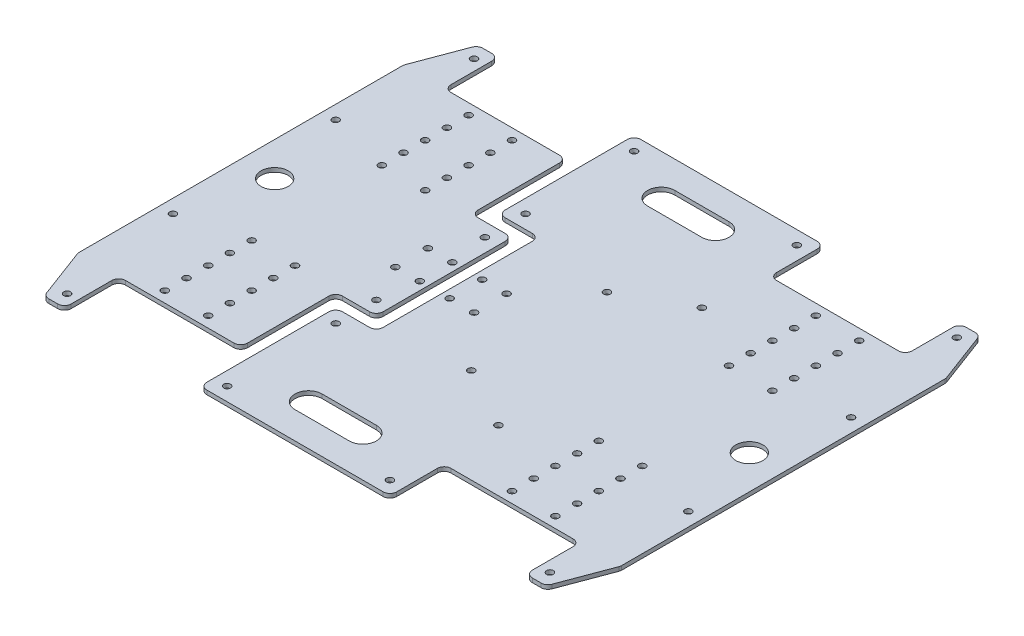
from build123d import *

# Parameters (mm, degrees)
SKETCH_1_R        = 2.5
SKETCH_1_R_2      = 10
EXTRUDE_1_DEPTH   = 3
EXTRUDE_1_2_DEPTH = 3


with BuildPart() as part:
    # 草图1 → 凸台-拉伸1 (new body)
    with BuildSketch(Plane(origin=(0, 0, 0), x_dir=(1, 0, 0), z_dir=(0, 1, 0))):
        with BuildLine():
            Line((-200, -119.093327091), (-200, 119.093327091))
            ThreePointArc((-200, 119.093327091), (-199.919767751, 119.985451119), (-199.681645888, 120.848944299))
            Line((-199.681645888, 120.848944299), (-186.216643547, 156.755617208))
            ThreePointArc((-186.216643547, 156.755617208), (-184.382971848, 159.109628088), (-181.534997659, 160))
            Line((-181.534997659, 160), (-175, 160))
            ThreePointArc((-175, 160), (-171.464466094, 158.535533906), (-170, 155))
            Line((-170, 155), (-170, 125))
            ThreePointArc((-170, 125), (-168.535533906, 121.464466094), (-165, 120))
            Line((-165, 120), (-85, 120))
            ThreePointArc((-85, 120), (-81.464466094, 118.535533906), (-80, 115))
            Line((-80, 115), (-80, 55))
            ThreePointArc((-80, 55), (-78.535533906, 51.464466094), (-75, 50))
            Line((-75, 50), (-55, 50))
            ThreePointArc((-55, 50), (-51.464466094, 48.535533906), (-50, 45))
            Line((-50, 45), (-50, -45))
            ThreePointArc((-50, -45), (-51.464466094, -48.535533906), (-55, -50))
            Line((-55, -50), (-75, -50))
            ThreePointArc((-75, -50), (-78.535533906, -51.464466094), (-80, -55))
            Line((-80, -55), (-80, -115))
            ThreePointArc((-80, -115), (-81.464466094, -118.535533906), (-85, -120))
            Line((-85, -120), (-165, -120))
            ThreePointArc((-165, -120), (-168.535533906, -121.464466094), (-170, -125))
            Line((-170, -125), (-170, -155))
            ThreePointArc((-170, -155), (-171.464466094, -158.535533906), (-175, -160))
            Line((-175, -160), (-181.534997659, -160))
            ThreePointArc((-181.534997659, -160), (-184.382971848, -159.109628088), (-186.216643547, -156.755617208))
            Line((-186.216643547, -156.755617208), (-199.681645888, -120.848944299))
            ThreePointArc((-199.681645888, -120.848944299), (-199.919767751, -119.985451119), (-200, -119.093327091))
        make_face()
        with Locations((-112, 112)):
            Circle(SKETCH_1_R, mode=Mode.SUBTRACT)
        with Locations((-144, 112)):
            Circle(SKETCH_1_R, mode=Mode.SUBTRACT)
        with Locations((-144, 96)):
            Circle(SKETCH_1_R, mode=Mode.SUBTRACT)
        with Locations((-144, 80)):
            Circle(SKETCH_1_R, mode=Mode.SUBTRACT)
        with Locations((-144, 64)):
            Circle(SKETCH_1_R, mode=Mode.SUBTRACT)
        with Locations((-144, 48)):
            Circle(SKETCH_1_R, mode=Mode.SUBTRACT)
        with Locations((-112, 96)):
            Circle(SKETCH_1_R, mode=Mode.SUBTRACT)
        with Locations((-112, 80)):
            Circle(SKETCH_1_R, mode=Mode.SUBTRACT)
        with Locations((-112, 64)):
            Circle(SKETCH_1_R, mode=Mode.SUBTRACT)
        with Locations((-112, 48)):
            Circle(SKETCH_1_R, mode=Mode.SUBTRACT)
        with Locations((-56, 12)):
            Circle(SKETCH_1_R, mode=Mode.SUBTRACT)
        with Locations((-74, 12)):
            Circle(SKETCH_1_R, mode=Mode.SUBTRACT)
        with Locations((-178, 150)):
            Circle(SKETCH_1_R, mode=Mode.SUBTRACT)
        with Locations((-60, 40)):
            Circle(SKETCH_1_R, mode=Mode.SUBTRACT)
        with Locations((-190, 60)):
            Circle(SKETCH_1_R, mode=Mode.SUBTRACT)
        with Locations((-175, 0)):
            Circle(SKETCH_1_R_2, mode=Mode.SUBTRACT)
        with Locations((-190, -60)):
            Circle(SKETCH_1_R, mode=Mode.SUBTRACT)
        with Locations((-60, -40)):
            Circle(SKETCH_1_R, mode=Mode.SUBTRACT)
        with Locations((-178, -150)):
            Circle(SKETCH_1_R, mode=Mode.SUBTRACT)
        with Locations((-74, -12)):
            Circle(SKETCH_1_R, mode=Mode.SUBTRACT)
        with Locations((-56, -12)):
            Circle(SKETCH_1_R, mode=Mode.SUBTRACT)
        with Locations((-112, -48)):
            Circle(SKETCH_1_R, mode=Mode.SUBTRACT)
        with Locations((-112, -64)):
            Circle(SKETCH_1_R, mode=Mode.SUBTRACT)
        with Locations((-112, -80)):
            Circle(SKETCH_1_R, mode=Mode.SUBTRACT)
        with Locations((-112, -96)):
            Circle(SKETCH_1_R, mode=Mode.SUBTRACT)
        with Locations((-144, -48)):
            Circle(SKETCH_1_R, mode=Mode.SUBTRACT)
        with Locations((-144, -64)):
            Circle(SKETCH_1_R, mode=Mode.SUBTRACT)
        with Locations((-144, -80)):
            Circle(SKETCH_1_R, mode=Mode.SUBTRACT)
        with Locations((-144, -96)):
            Circle(SKETCH_1_R, mode=Mode.SUBTRACT)
        with Locations((-144, -112)):
            Circle(SKETCH_1_R, mode=Mode.SUBTRACT)
        with Locations((-112, -112)):
            Circle(SKETCH_1_R, mode=Mode.SUBTRACT)
    extrude(amount=EXTRUDE_1_DEPTH)


with BuildPart() as body_2:
    # 草图1 → Extrude 1 2 (new body)
    with BuildSketch(Plane(origin=(0, 0, 0), x_dir=(1, 0, 0), z_dir=(0, 1, 0))):
        with BuildLine():
            Line((-70, 120), (-70, 65))
            ThreePointArc((-70, 65), (-68.535533906, 61.464466094), (-65, 60))
            Line((-65, 60), (-45, 60))
            ThreePointArc((-45, 60), (-41.464466094, 58.535533906), (-40, 55))
            Line((-40, 55), (-40, -55))
            ThreePointArc((-40, -55), (-41.464466094, -58.535533906), (-45, -60))
            Line((-45, -60), (-65, -60))
            ThreePointArc((-65, -60), (-68.535533906, -61.464466094), (-70, -65))
            Line((-70, -65), (-70, -120))
            Line((-70, -120), (-70, -155))
            ThreePointArc((-70, -155), (-68.535533906, -158.535533906), (-65, -160))
            Line((-65, -160), (65, -160))
            ThreePointArc((65, -160), (68.535533906, -158.535533906), (70, -155))
            Line((70, -155), (70, -125))
            ThreePointArc((70, -125), (71.464466094, -121.464466094), (75, -120))
            Line((75, -120), (165, -120))
            ThreePointArc((165, -120), (168.535533906, -121.464466094), (170, -125))
            Line((170, -125), (170, -155))
            ThreePointArc((170, -155), (171.464466094, -158.535533906), (175, -160))
            Line((175, -160), (181.534997659, -160))
            ThreePointArc((181.534997659, -160), (184.382971848, -159.109628088), (186.216643547, -156.755617208))
            Line((186.216643547, -156.755617208), (199.681645888, -120.848944299))
            ThreePointArc((199.681645888, -120.848944299), (199.919767751, -119.985451119), (200, -119.093327091))
            Line((200, -119.093327091), (200, 119.093327091))
            ThreePointArc((200, 119.093327091), (199.919767751, 119.985451119), (199.681645888, 120.848944299))
            Line((199.681645888, 120.848944299), (186.216643547, 156.755617208))
            ThreePointArc((186.216643547, 156.755617208), (184.382971848, 159.109628088), (181.534997659, 160))
            Line((181.534997659, 160), (175, 160))
            ThreePointArc((175, 160), (171.464466094, 158.535533906), (170, 155))
            Line((170, 155), (170, 125))
            ThreePointArc((170, 125), (168.535533906, 121.464466094), (165, 120))
            Line((165, 120), (75, 120))
            ThreePointArc((75, 120), (71.464466094, 121.464466094), (70, 125))
            Line((70, 125), (70, 155))
            ThreePointArc((70, 155), (68.535533906, 158.535533906), (65, 160))
            Line((65, 160), (-65, 160))
            ThreePointArc((-65, 160), (-68.535533906, 158.535533906), (-70, 155))
            Line((-70, 155), (-70, 120))
        make_face()
        with Locations((112, 112)):
            Circle(SKETCH_1_R, mode=Mode.SUBTRACT)
        with Locations((144, 112)):
            Circle(SKETCH_1_R, mode=Mode.SUBTRACT)
        with Locations((144, 96)):
            Circle(SKETCH_1_R, mode=Mode.SUBTRACT)
        with Locations((144, 80)):
            Circle(SKETCH_1_R, mode=Mode.SUBTRACT)
        with Locations((144, 64)):
            Circle(SKETCH_1_R, mode=Mode.SUBTRACT)
        with Locations((144, 48)):
            Circle(SKETCH_1_R, mode=Mode.SUBTRACT)
        with Locations((112, 96)):
            Circle(SKETCH_1_R, mode=Mode.SUBTRACT)
        with Locations((112, 80)):
            Circle(SKETCH_1_R, mode=Mode.SUBTRACT)
        with Locations((112, 64)):
            Circle(SKETCH_1_R, mode=Mode.SUBTRACT)
        with Locations((112, 48)):
            Circle(SKETCH_1_R, mode=Mode.SUBTRACT)
        with Locations((-34, 12)):
            Circle(SKETCH_1_R, mode=Mode.SUBTRACT)
        with Locations((-16, 12)):
            Circle(SKETCH_1_R, mode=Mode.SUBTRACT)
        with Locations((178, 150)):
            Circle(SKETCH_1_R, mode=Mode.SUBTRACT)
        with Locations((-60, 150)):
            Circle(SKETCH_1_R, mode=Mode.SUBTRACT)
        with Locations((60, 150)):
            Circle(SKETCH_1_R, mode=Mode.SUBTRACT)
        with Locations((-60, 70)):
            Circle(SKETCH_1_R, mode=Mode.SUBTRACT)
        with Locations((190, 60)):
            Circle(SKETCH_1_R, mode=Mode.SUBTRACT)
        with Locations((175, 0)):
            Circle(SKETCH_1_R_2, mode=Mode.SUBTRACT)
        with Locations((65, 75)):
            Circle(SKETCH_1_R, mode=Mode.SUBTRACT)
        with Locations((20, 50)):
            Circle(SKETCH_1_R, mode=Mode.SUBTRACT)
        with Locations((20, -50)):
            Circle(SKETCH_1_R, mode=Mode.SUBTRACT)
        with Locations((65, -75)):
            Circle(SKETCH_1_R, mode=Mode.SUBTRACT)
        with Locations((190, -60)):
            Circle(SKETCH_1_R, mode=Mode.SUBTRACT)
        with Locations((-60, -70)):
            Circle(SKETCH_1_R, mode=Mode.SUBTRACT)
        with Locations((60, -150)):
            Circle(SKETCH_1_R, mode=Mode.SUBTRACT)
        with Locations((-60, -150)):
            Circle(SKETCH_1_R, mode=Mode.SUBTRACT)
        with Locations((178, -150)):
            Circle(SKETCH_1_R, mode=Mode.SUBTRACT)
        with Locations((-16, -12)):
            Circle(SKETCH_1_R, mode=Mode.SUBTRACT)
        with Locations((-34, -12)):
            Circle(SKETCH_1_R, mode=Mode.SUBTRACT)
        with Locations((112, -48)):
            Circle(SKETCH_1_R, mode=Mode.SUBTRACT)
        with Locations((112, -64)):
            Circle(SKETCH_1_R, mode=Mode.SUBTRACT)
        with Locations((112, -80)):
            Circle(SKETCH_1_R, mode=Mode.SUBTRACT)
        with Locations((112, -96)):
            Circle(SKETCH_1_R, mode=Mode.SUBTRACT)
        with Locations((144, -48)):
            Circle(SKETCH_1_R, mode=Mode.SUBTRACT)
        with Locations((144, -64)):
            Circle(SKETCH_1_R, mode=Mode.SUBTRACT)
        with Locations((144, -80)):
            Circle(SKETCH_1_R, mode=Mode.SUBTRACT)
        with Locations((144, -96)):
            Circle(SKETCH_1_R, mode=Mode.SUBTRACT)
        with Locations((144, -112)):
            Circle(SKETCH_1_R, mode=Mode.SUBTRACT)
        with Locations((112, -112)):
            Circle(SKETCH_1_R, mode=Mode.SUBTRACT)
        with BuildLine():
            Line((-20, 140), (20, 140))
            ThreePointArc((20, 140), (30, 130), (20, 120))
            Line((20, 120), (-20, 120))
            ThreePointArc((-20, 120), (-30, 130), (-20, 140))
        make_face(mode=Mode.SUBTRACT)
        with BuildLine():
            Line((-20, -140), (20, -140))
            ThreePointArc((20, -140), (30, -130), (20, -120))
            Line((20, -120), (-20, -120))
            ThreePointArc((-20, -120), (-30, -130), (-20, -140))
        make_face(mode=Mode.SUBTRACT)
    extrude(amount=EXTRUDE_1_2_DEPTH)


solid = Compound([part.part, body_2.part])
